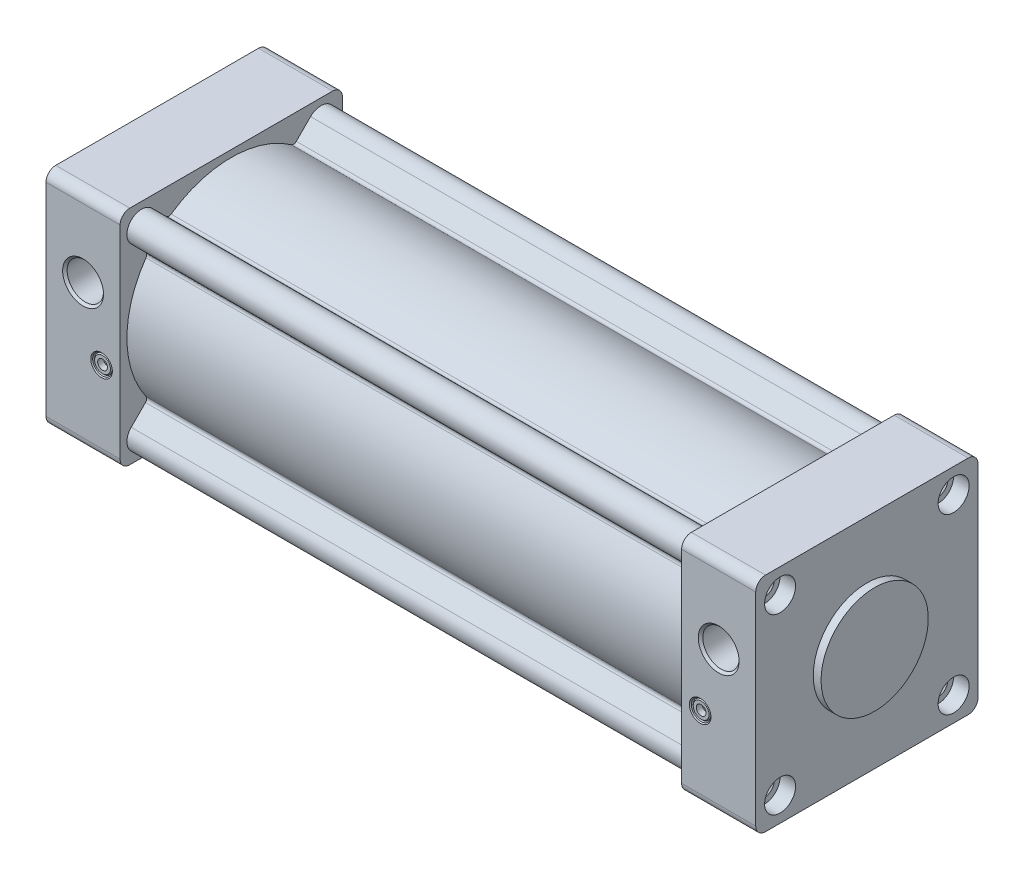
from build123d import *

# Parameters (mm, degrees)
EXTRUDE_1_DEPTH             = 38
SKETCH_3_R                  = 4.35
EXTRUDE_2_DEPTH             = 288
EXTRUDE_START               = -38
EXTRUDE_3_DEPTH             = 38
SKETCH_5_W                  = 42
SKETCH_5_H                  = 27.5
PATTERN_LINEAR_1_COUNT      = 2
PATTERN_LINEAR_1_PITCH      = 89
PATTERN_LINEAR_1_COUNT_DIR2 = 2
PATTERN_LINEAR_1_PITCH_DIR2 = 89
PATTERN_LINEAR_2_COUNT      = 2
PATTERN_LINEAR_2_PITCH      = 89
PATTERN_LINEAR_2_COUNT_DIR2 = 2
PATTERN_LINEAR_2_PITCH_DIR2 = 89


with BuildPart() as part:
    # 草图1 → 凸台-拉伸1 (new body)
    with BuildSketch(Plane(origin=(0, 0, 0), x_dir=(0, 0, -1), z_dir=(1, 0, 0))):
        with BuildLine():
            Line((-52, -57), (52, -57))
            ThreePointArc((52, -57), (55.535533906, -55.535533906), (57, -52))
            Line((57, -52), (57, 52))
            ThreePointArc((57, 52), (55.535533906, 55.535533906), (52, 57))
            Line((52, 57), (-52, 57))
            ThreePointArc((-52, 57), (-55.535533906, 55.535533906), (-57, 52))
            Line((-57, 52), (-57, -52))
            ThreePointArc((-57, -52), (-55.535533906, -55.535533906), (-52, -57))
        make_face()
    extrude(amount=EXTRUDE_1_DEPTH)

    # 草图2 → 旋转1 (revolve)
    with BuildSketch(Plane(origin=(0, 0, 0), x_dir=(1, 0, 0), z_dir=(0, 1, 0))):
        with BuildLine():
            Line((-20, 0), (-20, 23))
            ThreePointArc((-20, 23), (-19.707106781, 23.707106781), (-19, 24))
            Line((-19, 24), (-5, 24))
            Line((-5, 24), (-5, 26.5))
            ThreePointArc((-5, 26.5), (-4.707106781, 27.207106781), (-4, 27.5))
            Line((-4, 27.5), (38, 27.5))
            Line((38, 27.5), (38, 0))
            Line((38, 0), (-20, 0))
        make_face()
    revolve(axis=Axis((38, 0, 0), (-1, 0, 0)))

    # 草图3 → 凸台-拉伸2 (add)
    with BuildSketch(Plane(origin=(38, 0, 0), x_dir=(0, 0, -1), z_dir=(1, 0, 0))):
        with BuildLine():
            Line((-43.968530717, -33.361928999), (-51.303300859, -40.696699141))
            ThreePointArc((-51.303300859, -40.696699141), (-51.303300859, -51.303300859), (-40.696699141, -51.303300859))
            Line((-40.696699141, -51.303300859), (-33.361928999, -43.968530717))
            ThreePointArc((-33.361928999, -43.968530717), (-32.119521583, -43.390137282), (-30.796446235, -43.747330196))
            ThreePointArc((-30.796446235, -43.747330196), (1.08e-07, -53.5), (30.796446412, -43.747330071))
            ThreePointArc((30.796446412, -43.747330071), (32.119521691, -43.390137291), (33.361928999, -43.968530717))
            Line((33.361928999, -43.968530717), (40.696699141, -51.303300859))
            ThreePointArc((40.696699141, -51.303300859), (51.303300859, -51.303300859), (51.303300859, -40.696699141))
            Line((51.303300859, -40.696699141), (43.968530717, -33.361928999))
            ThreePointArc((43.968530717, -33.361928999), (43.390137282, -32.119521583), (43.747330196, -30.796446235))
            ThreePointArc((43.747330196, -30.796446235), (53.5, 1.08e-07), (43.747330071, 30.796446412))
            ThreePointArc((43.747330071, 30.796446412), (43.390137291, 32.119521691), (43.968530717, 33.361928999))
            Line((43.968530717, 33.361928999), (51.303300859, 40.696699141))
            ThreePointArc((51.303300859, 40.696699141), (51.303300859, 51.303300859), (40.696699141, 51.303300859))
            Line((40.696699141, 51.303300859), (33.361928999, 43.968530717))
            ThreePointArc((33.361928999, 43.968530717), (32.119521583, 43.390137282), (30.796446235, 43.747330196))
            ThreePointArc((30.796446235, 43.747330196), (-1.08e-07, 53.5), (-30.796446412, 43.747330071))
            ThreePointArc((-30.796446412, 43.747330071), (-32.119521691, 43.390137291), (-33.361928999, 43.968530717))
            Line((-33.361928999, 43.968530717), (-40.696699141, 51.303300859))
            ThreePointArc((-40.696699141, 51.303300859), (-51.303300859, 51.303300859), (-51.303300859, 40.696699141))
            Line((-51.303300859, 40.696699141), (-43.968530717, 33.361928999))
            ThreePointArc((-43.968530717, 33.361928999), (-43.390137282, 32.119521583), (-43.747330196, 30.796446235))
            ThreePointArc((-43.747330196, 30.796446235), (-53.5, -1.08e-07), (-43.747330071, -30.796446412))
            ThreePointArc((-43.747330071, -30.796446412), (-43.390137291, -32.119521691), (-43.968530717, -33.361928999))
        make_face()
        with Locations((44.5, 44.5)):
            Circle(SKETCH_3_R, mode=Mode.SUBTRACT)
        with Locations((44.5, -44.5)):
            Circle(SKETCH_3_R, mode=Mode.SUBTRACT)
        with Locations((-44.5, 44.5)):
            Circle(SKETCH_3_R, mode=Mode.SUBTRACT)
        with Locations((-44.5, -44.5)):
            Circle(SKETCH_3_R, mode=Mode.SUBTRACT)
    extrude(amount=EXTRUDE_2_DEPTH)

    # 草图4 → 凸台-拉伸3 (add)
    with BuildSketch(Plane(origin=(364, 0, 0), x_dir=(0, 0, -1), z_dir=(1, 0, 0)).offset(EXTRUDE_START)):
        with BuildLine():
            Line((-52, -57), (52, -57))
            ThreePointArc((52, -57), (55.535533906, -55.535533906), (57, -52))
            Line((57, -52), (57, 52))
            ThreePointArc((57, 52), (55.535533906, 55.535533906), (52, 57))
            Line((52, 57), (-52, 57))
            ThreePointArc((-52, 57), (-55.535533906, 55.535533906), (-57, 52))
            Line((-57, 52), (-57, -52))
            ThreePointArc((-57, -52), (-55.535533906, -55.535533906), (-52, -57))
        make_face()
    extrude(amount=EXTRUDE_3_DEPTH)

    # 草图5 → 旋转2 (revolve)
    with BuildSketch(Plane.XY):
        with Locations((347, 13.75)):
            Rectangle(SKETCH_5_W, SKETCH_5_H)
    revolve(axis=Axis((368, 0, 0), (-1, 0, 0)))

    # 草图6 → 切除-旋转1 (revolve, cut)
    with BuildSketch(Plane(origin=(0, 17, 0), x_dir=(1, 0, 0), z_dir=(0, 1, 0))):
        Polygon((19, -57), (8.5225, -57), (9.6845, -55.838), (9.6845, -35), (19, -29.621693567), align=None)
    revolve(axis=Axis((19, 17, 29.621693567), (0, 0, 1)), mode=Mode.SUBTRACT)

    # 草图7 → 切除-旋转2 (revolve, cut)
    with BuildSketch(Plane(origin=(0, 17, 0), x_dir=(1, 0, 0), z_dir=(0, 1, 0))):
        Polygon((345, -57), (334.5225, -57), (335.6845, -55.838), (335.6845, -35), (345, -29.621693567), align=None)
    revolve(axis=Axis((345, 17, 29.621693567), (0, 0, 1)), mode=Mode.SUBTRACT)

    # 草图8 → 切除-旋转3 (revolve, cut)
    with BuildSketch(Plane(origin=(0, -15, 0), x_dir=(1, 0, 0), z_dir=(0, 1, 0))):
        Polygon((28.5, -57), (22.95, -57), (23.45, -56.5), (23.45, -53.5), (23.95, -53.5), (23.95, -56), (24.45, -56.5), (26, -56.5), (26, -53.5), (28.5, -53.5), align=None)
    revolve(axis=Axis((28.5, -15, 53.5), (0, 0, 1)), mode=Mode.SUBTRACT)

    # 草图9 → 切除-旋转4 (revolve, cut)
    with BuildSketch(Plane(origin=(0, -15, 0), x_dir=(1, 0, 0), z_dir=(0, 1, 0))):
        Polygon((335.5, -57), (329.95, -57), (330.45, -56.5), (330.45, -53.5), (330.95, -53.5), (330.95, -56), (331.45, -56.5), (333, -56.5), (333, -53.5), (335.5, -53.5), align=None)
    revolve(axis=Axis((335.5, -15, 53.5), (0, 0, 1)), mode=Mode.SUBTRACT)

    # 草图10 → 切除-旋转5 (revolve, cut)
    with BuildSketch(Plane.XY.offset(-44.5)):
        Polygon((22, -44.5), (22, -48.688), (8.812, -48.688), (8, -49.5), (8, -52.45), (0, -52.45), (0, -44.5), align=None)
    cut_revolve_5 = revolve(axis=Axis((0, -44.5, -44.5), (1, 0, 0)), mode=Mode.SUBTRACT)

    # 阵列(线性)1: Cut-Revolve 5 2 × 2
    with Locations(*[(0, i * PATTERN_LINEAR_1_PITCH, j * PATTERN_LINEAR_1_PITCH_DIR2) for i in range(PATTERN_LINEAR_1_COUNT) for j in range(PATTERN_LINEAR_1_COUNT_DIR2) if (i, j) != (0, 0)]):
        add(cut_revolve_5, mode=Mode.SUBTRACT)

    # 草图12 → 切除-旋转6 (revolve, cut)
    with BuildSketch(Plane.XY.offset(-44.5)):
        Polygon((364, -44.5), (364, -52.45), (356, -52.45), (356, -49.5), (355.188, -48.688), (342, -48.688), (342, -44.5), align=None)
    cut_revolve_6 = revolve(axis=Axis((342, -44.5, -44.5), (1, 0, 0)), mode=Mode.SUBTRACT)

    # 阵列(线性)2: Cut-Revolve 6 2 × 2
    with Locations(*[(0, i * PATTERN_LINEAR_2_PITCH, j * PATTERN_LINEAR_2_PITCH_DIR2) for i in range(PATTERN_LINEAR_2_COUNT) for j in range(PATTERN_LINEAR_2_COUNT_DIR2) if (i, j) != (0, 0)]):
        add(cut_revolve_6, mode=Mode.SUBTRACT)

    # 草图14 → 切除-旋转7 (revolve, cut)
    with BuildSketch(Plane.XY):
        Polygon((-20, 0), (-20, 15), (-1, 15), (-1, 18.2), (35, 18.2), (35, 50), (329, 50), (329, 18.2), (365, 18.2), (365, 0), align=None)
    revolve(axis=Axis((365, 0, 0), (-1, 0, 0)), mode=Mode.SUBTRACT)


solid = part.part
